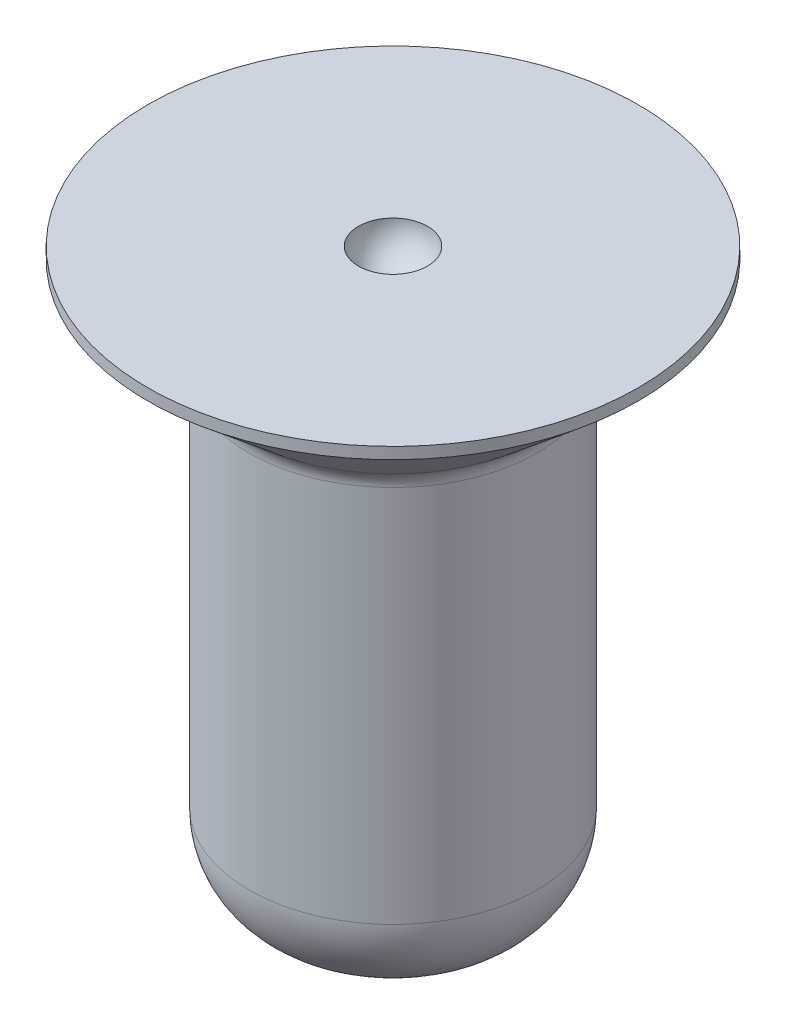
from build123d import *


with BuildPart() as part:
    # Sketch1 → Revolve1 (revolve)
    with BuildSketch(Plane.XY):
        with BuildLine():
            Line((0, -0.381), (0, -6.35))
            Line((0, -6.35), (0.5969, -6.35))
            ThreePointArc((0.5969, -6.35), (1.297359977, -6.059859977), (1.5875, -5.3594))
            Line((1.5875, -5.3594), (1.5875, -1.184098677))
            ThreePointArc((1.5875, -1.184098677), (1.611297822, -1.076753638), (1.678231947, -0.989523388))
            Line((1.678231947, -0.989523388), (2.706147294, -0.127))
            Line((2.706147294, -0.127), (2.706147294, 0))
            Line((2.706147294, 0), (0.381, 0))
            ThreePointArc((0.381, 0), (0.269407684, -0.269407684), (0, -0.381))
        make_face()
    revolve(axis=Axis((0, 28.449499207, 0), (0, -1, 0)))


solid = part.part
